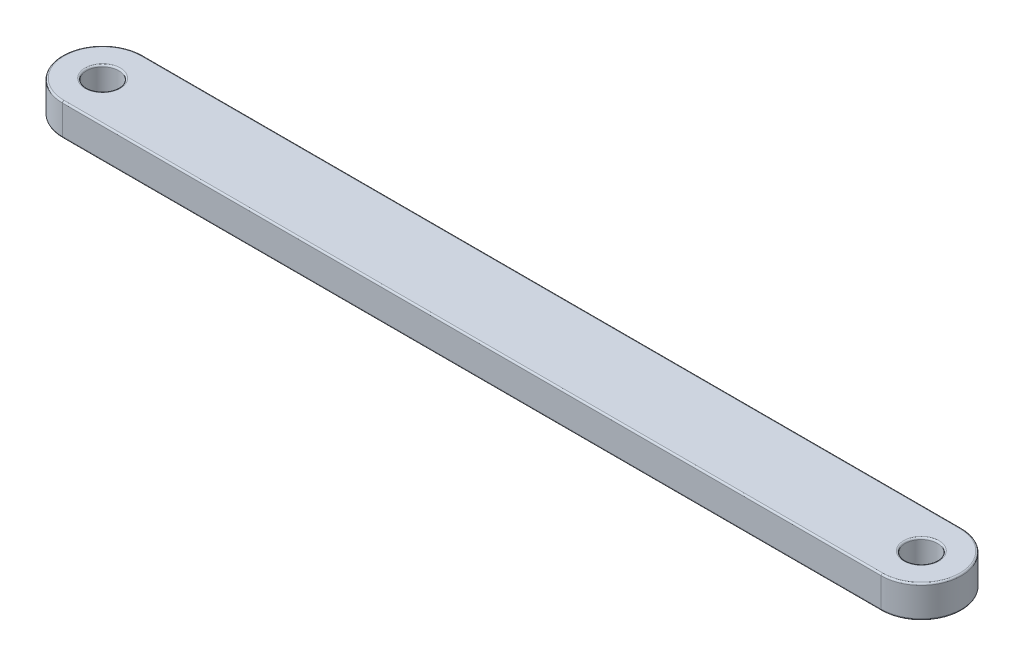
from build123d import *

# Parameters (mm, degrees)
SKETCH1_R           = 10
BOSS_EXTRUDE1_DEPTH = 20
FILLET1_R           = 1


with BuildPart() as part:
    # Sketch1 → Boss-Extrude1 (new body)
    with BuildSketch(Plane(origin=(0, 0, 0), x_dir=(1, 0, 0), z_dir=(0, 1, 0))):
        with BuildLine():
            Line((-255, 25), (255, 25))
            ThreePointArc((255, 25), (280, 0), (255, -25))
            Line((255, -25), (-255, -25))
            ThreePointArc((-255, -25), (-280, 0), (-255, 25))
        make_face()
        with Locations((-255, 0)):
            Circle(SKETCH1_R, mode=Mode.SUBTRACT)
        with Locations((255, 0)):
            Circle(SKETCH1_R, mode=Mode.SUBTRACT)
    extrude(amount=BOSS_EXTRUDE1_DEPTH)

    # Fillet1
    fillet1_edges = [part.edges().sort_by_distance(p)[0] for p in [
        (-265, 0, 0),
        (-265, 20, 0),
        (280, 20, 0),
        (245, 0, 0),
        (245, 20, 0),
        (0, 20, -25),
        (-280, 20, 0),
        (0, 0, -25),
        (280, 0, 0),
        (0, 0, 25),
        (-280, 0, 0),
        (0, 20, 25),
    ]]
    fillet(fillet1_edges, radius=FILLET1_R)


solid = part.part
